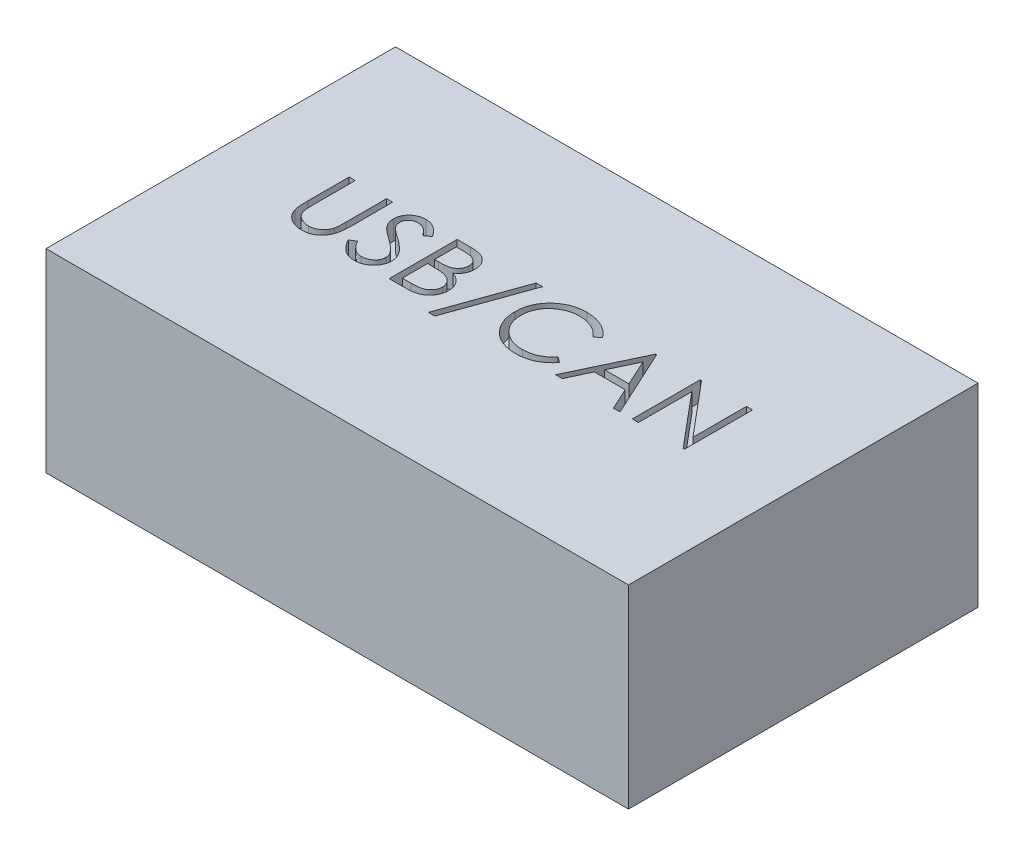
from build123d import *

# Parameters (mm, degrees)
SKETCH1_W           = 30
SKETCH1_H           = 18
BOSS_EXTRUDE1_DEPTH = 10
CUT_EXTRUDE1_DEPTH  = 1


with BuildPart() as part:
    # Sketch1 → Boss-Extrude1 (new body)
    with BuildSketch(Plane(origin=(0, 0, 0), x_dir=(1, 0, 0), z_dir=(0, 1, 0))):
        with Locations((15, 9)):
            Rectangle(SKETCH1_W, SKETCH1_H)
    extrude(amount=BOSS_EXTRUDE1_DEPTH)

    # Sketch2 → Cut-Extrude1 (cut)
    with BuildSketch(Plane(origin=(0, 10, 0), x_dir=(1, 0, 0), z_dir=(0, 1, 0))):
        with BuildLine():
            Line((4.612179487, 11), (4.926282051, 11))
            Line((4.926282051, 11), (4.926282051, 8.902944712))
            add(Edge.make_bspline(
                [(4.926282051, 8.902944712), (4.926235307, 8.873263976), (4.926146603, 8.816939665), (4.926739116, 8.736771364), (4.928398485, 8.665498905), (4.929444644, 8.602847558), (4.931771978, 8.54910481), (4.933670025, 8.5039795), (4.936110582, 8.467685297), (4.939043699, 8.446504371), (4.940304487, 8.43739984)],
                knots=[0, 0, 0, 0, 8.9042e-05, 0.000168973, 0.000240502, 0.000302917, 0.000356945, 0.000401866, 0.000438432, 0.000465999, 0.000465999, 0.000465999, 0.000465999], degree=3))
            add(Edge.make_bspline(
                [(4.940304487, 8.43739984), (4.945481946, 8.404553076), (4.955545132, 8.340710347), (4.98119151, 8.249802065), (5.017009011, 8.167870607), (5.059452054, 8.092359316), (5.115384665, 8.025369956), (5.1823882, 7.963658303), (5.263565969, 7.909686499), (5.353826575, 7.860335687), (5.451111812, 7.820670604), (5.550523079, 7.79067724), (5.650566058, 7.77239834), (5.717542223, 7.770281801), (5.750801282, 7.769230769)],
                knots=[0, 0, 0, 0, 9.971e-05, 0.000193801, 0.000282365, 0.000367504, 0.000452699, 0.000543015, 0.000639862, 0.000744331, 0.000851226, 0.000954377, 0.001055468, 0.001155185, 0.001155185, 0.001155185, 0.001155185], degree=3))
            add(Edge.make_bspline(
                [(5.750801282, 7.769230769), (5.779355022, 7.77030462), (5.836297584, 7.772446118), (5.920904015, 7.785707549), (6.003304124, 7.809608115), (6.083904804, 7.840447873), (6.159455788, 7.881195464), (6.22999923, 7.928266303), (6.292963164, 7.98347718), (6.350421162, 8.044577524), (6.400456098, 8.113517324), (6.44382724, 8.188795462), (6.479353169, 8.271544809), (6.496896694, 8.329699231), (6.505909455, 8.359575321)],
                knots=[0, 0, 0, 0, 8.5678e-05, 0.00017086, 0.000256092, 0.000342674, 0.000429242, 0.000513055, 0.000596556, 0.000679898, 0.000764179, 0.00085149, 0.000940054, 0.001033621, 0.001033621, 0.001033621, 0.001033621], degree=3))
            add(Edge.make_bspline(
                [(6.505909455, 8.359575321), (6.50890958, 8.371923895), (6.515595069, 8.399441495), (6.521842114, 8.445962785), (6.528348639, 8.500852149), (6.532863209, 8.564503962), (6.537264429, 8.636704935), (6.539897502, 8.717831192), (6.541114535, 8.807588153), (6.541477216, 8.870225315), (6.541666667, 8.902944712)],
                knots=[0, 0, 0, 0, 3.81e-05, 8.4902e-05, 0.000140649, 0.000203941, 0.000276279, 0.000357657, 0.000447412, 0.000545571, 0.000545571, 0.000545571, 0.000545571], degree=3))
            Line((6.541666667, 8.902944712), (6.541666667, 11))
            Line((6.541666667, 11), (6.855769231, 11))
            Line((6.855769231, 11), (6.855769231, 8.886117788))
            add(Edge.make_bspline(
                [(6.855769231, 8.886117788), (6.85551511, 8.84801941), (6.855019179, 8.773668107), (6.850718603, 8.664716748), (6.843861603, 8.561363766), (6.834173515, 8.46359527), (6.821336512, 8.371761111), (6.807061291, 8.285056342), (6.788881758, 8.20410335), (6.767648357, 8.128270932), (6.743374809, 8.056085419), (6.71193366, 7.987576804), (6.67650916, 7.920662404), (6.634494508, 7.856354295), (6.587283125, 7.794367742), (6.533831444, 7.735078667), (6.475907283, 7.677539621), (6.412547724, 7.623226555), (6.344797198, 7.573417878), (6.272857241, 7.529620107), (6.197280471, 7.492596489), (6.118263345, 7.462120565), (6.035772142, 7.439205966), (5.949804782, 7.42213081), (5.860165589, 7.412428513), (5.799200933, 7.410986582), (5.768329327, 7.41025641)],
                knots=[0, 0, 0, 0, 0.000114291, 0.000223047, 0.000327049, 0.000424998, 0.000517708, 0.000605194, 0.000688542, 0.000766455, 0.0008414, 0.000916717, 0.000992315, 0.001068354, 0.001146882, 0.001225836, 0.001307639, 0.001391671, 0.001475952, 0.001559641, 0.001643989, 0.001728103, 0.001813335, 0.001900511, 0.00199079, 0.002083404, 0.002083404, 0.002083404, 0.002083404], degree=3))
            add(Edge.make_bspline(
                [(5.768329327, 7.41025641), (5.734660224, 7.411041176), (5.668601565, 7.412580882), (5.571263498, 7.421403632), (5.477949302, 7.438022027), (5.387673425, 7.45918197), (5.301664928, 7.488365708), (5.218771483, 7.522463832), (5.140412802, 7.564341093), (5.065317674, 7.610934486), (4.995492917, 7.663359124), (4.931395514, 7.720499298), (4.872919644, 7.781439675), (4.821050947, 7.846840041), (4.774930063, 7.916191748), (4.735199849, 7.989690988), (4.701086605, 8.067309304), (4.683480038, 8.121262504), (4.674579327, 8.14853766)],
                knots=[0, 0, 0, 0, 0.000101022, 0.000198206, 0.000292839, 0.000385177, 0.00047608, 0.000565014, 0.000653769, 0.000742283, 0.000829923, 0.000915339, 0.000999643, 0.001082971, 0.00116542, 0.001249186, 0.001333332, 0.001419362, 0.001419362, 0.001419362, 0.001419362], degree=3))
            add(Edge.make_bspline(
                [(4.674579327, 8.14853766), (4.669402169, 8.167170235), (4.658172797, 8.207584704), (4.6461475, 8.274471192), (4.636038418, 8.35148611), (4.62653286, 8.438634728), (4.620923902, 8.535984595), (4.616006463, 8.643493511), (4.612144844, 8.761291472), (4.612167617, 8.843345988), (4.612179487, 8.886117788)],
                knots=[0, 0, 0, 0, 5.799e-05, 0.000125782, 0.000203619, 0.000291034, 0.000388694, 0.000496078, 0.000613919, 0.000742226, 0.000742226, 0.000742226, 0.000742226], degree=3))
            Line((4.612179487, 8.886117788), (4.612179487, 11))
        make_face()
        with BuildLine():
            Line((7.394230769, 8.175180288), (7.690104167, 8.352564103))
            add(Edge.make_bspline(
                [(7.690104167, 8.352564103), (7.717622404, 8.306499718), (7.770346285, 8.218242134), (7.858297644, 8.098984093), (7.949430555, 7.997621937), (8.044419888, 7.914745329), (8.142685837, 7.849496442), (8.24486989, 7.803294211), (8.350627701, 7.774478235), (8.422601522, 7.770978149), (8.458533654, 7.769230769)],
                knots=[0, 0, 0, 0, 0.000160901, 0.00030828, 0.000443778, 0.00056903, 0.000685513, 0.000796284, 0.00090427, 0.001011928, 0.001011928, 0.001011928, 0.001011928], degree=3))
            add(Edge.make_bspline(
                [(8.458533654, 7.769230769), (8.489220514, 7.770085442), (8.550057287, 7.771779832), (8.63961953, 7.788060634), (8.726601333, 7.813072763), (8.80920997, 7.848893694), (8.886305585, 7.89223218), (8.95391228, 7.944578358), (9.012358393, 8.003184563), (9.060167508, 8.068567218), (9.096847543, 8.138884367), (9.125039612, 8.211060318), (9.140684685, 8.286228886), (9.143041439, 8.336839349), (9.144230769, 8.362379808)],
                knots=[0, 0, 0, 0, 9.1978e-05, 0.000182347, 0.000272202, 0.000362975, 0.000451852, 0.000536835, 0.000618639, 0.000699414, 0.000778765, 0.000855983, 0.0009312, 0.001007828, 0.001007828, 0.001007828, 0.001007828], degree=3))
            add(Edge.make_bspline(
                [(9.144230769, 8.362379808), (9.142756459, 8.391520657), (9.1397594, 8.450759747), (9.11442792, 8.5381594), (9.074578673, 8.62465197), (9.03781603, 8.678153235), (9.018729968, 8.705929487)],
                knots=[0, 0, 0, 0, 8.7281e-05, 0.000177429, 0.000270909, 0.000371844, 0.000371844, 0.000371844, 0.000371844], degree=3))
            add(Edge.make_bspline(
                [(9.018729968, 8.705929487), (9.003059354, 8.725976311), (8.970160859, 8.768062109), (8.913603347, 8.830707345), (8.847237233, 8.895325764), (8.773333678, 8.964384821), (8.689200589, 9.034672617), (8.597473074, 9.109540895), (8.495809215, 9.186142472), (8.424509719, 9.237515038), (8.387720353, 9.264022436)],
                knots=[0, 0, 0, 0, 7.6319e-05, 0.000160223, 0.000252933, 0.000354147, 0.000463581, 0.000581729, 0.000709336, 0.000845369, 0.000845369, 0.000845369, 0.000845369], degree=3))
            add(Edge.make_bspline(
                [(8.387720353, 9.264022436), (8.350896356, 9.290251024), (8.28049168, 9.340398086), (8.182033097, 9.41482237), (8.093988634, 9.482866239), (8.016749618, 9.545170251), (7.950350021, 9.601742856), (7.89426661, 9.652040795), (7.849928053, 9.697424356), (7.825272472, 9.726865698), (7.814202724, 9.740084135)],
                knots=[0, 0, 0, 0, 0.000135623, 0.000259301, 0.000370234, 0.000469439, 0.00055697, 0.000631911, 0.000695377, 0.00074709, 0.00074709, 0.00074709, 0.00074709], degree=3))
            add(Edge.make_bspline(
                [(7.814202724, 9.740084135), (7.798730179, 9.760685171), (7.768301342, 9.801199875), (7.728135337, 9.864524733), (7.693996174, 9.929347998), (7.667233842, 9.995843863), (7.644697623, 10.063078792), (7.629539692, 10.131930038), (7.620048296, 10.202088656), (7.619076309, 10.249302157), (7.618589744, 10.272936699)],
                knots=[0, 0, 0, 0, 7.727e-05, 0.000151962, 0.000224716, 0.000296717, 0.00036678, 0.0004372, 0.000507902, 0.000578771, 0.000578771, 0.000578771, 0.000578771], degree=3))
            add(Edge.make_bspline(
                [(7.618589744, 10.272936699), (7.619894953, 10.309966473), (7.622477473, 10.383234537), (7.64431799, 10.490265367), (7.678790884, 10.592451785), (7.727085771, 10.688782118), (7.789343124, 10.776748099), (7.861389099, 10.857361586), (7.947200585, 10.925130168), (8.041353208, 10.984342227), (8.14440958, 11.030688152), (8.252400484, 11.065649132), (8.365497556, 11.08545839), (8.44210069, 11.088301155), (8.480969551, 11.08974359)],
                knots=[0, 0, 0, 0, 0.000110999, 0.000219625, 0.000326272, 0.00043382, 0.000541574, 0.000648775, 0.000756959, 0.000868438, 0.000981703, 0.00109501, 0.001208203, 0.0013248, 0.0013248, 0.0013248, 0.0013248], degree=3))
            add(Edge.make_bspline(
                [(8.480969551, 11.08974359), (8.522213652, 11.088321038), (8.604235003, 11.085492037), (8.724884219, 11.060894506), (8.841044935, 11.020193834), (8.9344882, 10.974005176), (9.007620962, 10.92787376), (9.063393694, 10.885853936), (9.119911145, 10.837478827), (9.1776292, 10.782619581), (9.235569859, 10.72077283), (9.294593312, 10.652362141), (9.35483758, 10.577805585), (9.393593441, 10.524581085), (9.413461538, 10.497295673)],
                knots=[0, 0, 0, 0, 0.000123638, 0.000245877, 0.000367608, 0.000492088, 0.000557638, 0.000626769, 0.000701372, 0.00078072, 0.000865532, 0.000955497, 0.001051745, 0.001152989, 0.001152989, 0.001152989, 0.001152989], degree=3))
            Line((9.413461538, 10.497295673), (9.129507212, 10.282051282))
            add(Edge.make_bspline(
                [(9.129507212, 10.282051282), (9.112361279, 10.304139972), (9.079342222, 10.346677626), (9.029212735, 10.406248941), (8.981964087, 10.460665421), (8.935413687, 10.507930549), (8.892020056, 10.550632682), (8.849903014, 10.587192439), (8.809668662, 10.617968034), (8.758951752, 10.650811594), (8.695234034, 10.683368098), (8.615249497, 10.710917176), (8.531663222, 10.727472238), (8.474733591, 10.729661126), (8.445913462, 10.730769231)],
                knots=[0, 0, 0, 0, 8.3877e-05, 0.000161528, 0.000233552, 0.000299993, 0.000360485, 0.000416152, 0.000467195, 0.000512312, 0.000597287, 0.000681099, 0.000765389, 0.000851809, 0.000851809, 0.000851809, 0.000851809], degree=3))
            add(Edge.make_bspline(
                [(8.445913462, 10.730769231), (8.409756939, 10.729557531), (8.340032492, 10.727220882), (8.241042256, 10.701700896), (8.151948331, 10.661519036), (8.075395765, 10.605204058), (8.011658788, 10.538483065), (7.96555333, 10.46170421), (7.937803165, 10.376921808), (7.934416885, 10.317780151), (7.932692308, 10.287660256)],
                knots=[0, 0, 0, 0, 0.000108248, 0.000208746, 0.00030443, 0.000399793, 0.000492054, 0.00057947, 0.000666386, 0.000756591, 0.000756591, 0.000756591, 0.000756591], degree=3))
            add(Edge.make_bspline(
                [(7.932692308, 10.287660256), (7.933085434, 10.268908778), (7.93387233, 10.231375158), (7.944847128, 10.175923736), (7.958946457, 10.120612397), (7.981289089, 10.065689814), (8.012134392, 10.010195455), (8.052639568, 9.953173718), (8.10365288, 9.894122009), (8.142729893, 9.855714635), (8.163361378, 9.835436699)],
                knots=[0, 0, 0, 0, 5.616e-05, 0.000112411, 0.000169046, 0.000227244, 0.000289691, 0.000359134, 0.000436702, 0.000523463, 0.000523463, 0.000523463, 0.000523463], degree=3))
            add(Edge.make_bspline(
                [(8.163361378, 9.835436699), (8.171022751, 9.828599673), (8.189224418, 9.812356465), (8.222500343, 9.785764184), (8.266443142, 9.752961412), (8.319905343, 9.712374095), (8.383872705, 9.665292633), (8.458352261, 9.612319021), (8.542513794, 9.551733562), (8.60223571, 9.509376021), (8.633814103, 9.486979167)],
                knots=[0, 0, 0, 0, 3.0802e-05, 7.3177e-05, 0.000127725, 0.000195314, 0.000274544, 0.000365991, 0.000469501, 0.000585644, 0.000585644, 0.000585644, 0.000585644], degree=3))
            add(Edge.make_bspline(
                [(8.633814103, 9.486979167), (8.671800016, 9.459337807), (8.745354472, 9.405814145), (8.850012052, 9.325398465), (8.94490586, 9.246750697), (9.030369064, 9.17037309), (9.107245972, 9.096844997), (9.174683693, 9.025281816), (9.233369373, 8.956196244), (9.296548592, 8.867623668), (9.361106411, 8.758842584), (9.416547919, 8.625564345), (9.451506266, 8.491768025), (9.456077782, 8.401841188), (9.458333333, 8.357471955)],
                knots=[0, 0, 0, 0, 0.000140932, 0.000272896, 0.000395881, 0.000510584, 0.000616697, 0.000714904, 0.000805482, 0.000888372, 0.001041088, 0.001183793, 0.001320341, 0.001453327, 0.001453327, 0.001453327, 0.001453327], degree=3))
            add(Edge.make_bspline(
                [(9.458333333, 8.357471955), (9.457676195, 8.32609359), (9.45637468, 8.263946206), (9.441413766, 8.17269113), (9.419494101, 8.08406026), (9.386456867, 7.999149147), (9.346133709, 7.916404385), (9.294967461, 7.837996484), (9.235659776, 7.762190086), (9.167626011, 7.691006594), (9.093180109, 7.625660398), (9.014496415, 7.567531337), (8.931446142, 7.519063014), (8.844479825, 7.479512172), (8.753577488, 7.448578654), (8.658769704, 7.426165785), (8.559900193, 7.412410074), (8.492699712, 7.410982313), (8.458533654, 7.41025641)],
                knots=[0, 0, 0, 0, 9.4044e-05, 0.000186263, 0.000276729, 0.000367488, 0.000459046, 0.000552398, 0.000647774, 0.000747454, 0.000847311, 0.000944634, 0.001040472, 0.001135227, 0.001230788, 0.001328063, 0.00142712, 0.00152957, 0.00152957, 0.00152957, 0.00152957], degree=3))
            add(Edge.make_bspline(
                [(8.458533654, 7.41025641), (8.432098311, 7.410767592), (8.379560551, 7.411783517), (8.301851069, 7.420764798), (8.22571148, 7.433471901), (8.152097198, 7.453645971), (8.080059786, 7.478122948), (8.009912552, 7.508261281), (7.941621498, 7.544378482), (7.874803915, 7.585673507), (7.80962974, 7.633731252), (7.746710272, 7.689704748), (7.683981087, 7.752050253), (7.62329369, 7.822460816), (7.563420546, 7.899798899), (7.505542137, 7.984788083), (7.448460419, 8.076965436), (7.412644951, 8.141830522), (7.394230769, 8.175180288)],
                knots=[0, 0, 0, 0, 7.9276e-05, 0.000157554, 0.000234438, 0.000310629, 0.000386236, 0.000462555, 0.000539392, 0.000617798, 0.000698008, 0.000781971, 0.000870217, 0.00096315, 0.001060616, 0.001163492, 0.001271478, 0.00138575, 0.00138575, 0.00138575, 0.00138575], degree=3))
        make_face()
        with BuildLine():
            Line((10.176282051, 11), (10.859174679, 11))
            add(Edge.make_bspline(
                [(10.859174679, 11), (10.892603158, 10.99982425), (10.957395868, 10.999483602), (11.05161531, 10.99420047), (11.13986412, 10.986996801), (11.222167893, 10.975566708), (11.298488595, 10.961774931), (11.369056232, 10.945073115), (11.433646405, 10.925046501), (11.510759141, 10.89320022), (11.598679802, 10.845877051), (11.693878195, 10.775948486), (11.775282434, 10.690416023), (11.845468751, 10.593933368), (11.901269871, 10.487797596), (11.941639168, 10.374538407), (11.967197044, 10.255616665), (11.969825478, 10.173973487), (11.971153846, 10.13271234)],
                knots=[0, 0, 0, 0, 0.00010027, 0.000194349, 0.000283026, 0.000365821, 0.000443519, 0.000515622, 0.000583254, 0.00064614, 0.000765662, 0.000881909, 0.000998927, 0.001118415, 0.001238844, 0.00135727, 0.001478274, 0.001601912, 0.001601912, 0.001601912, 0.001601912], degree=3))
            add(Edge.make_bspline(
                [(11.971153846, 10.13271234), (11.970060628, 10.094059784), (11.96791235, 10.018103867), (11.947369591, 9.907009758), (11.915208923, 9.801258539), (11.870503673, 9.701236154), (11.812401677, 9.60920254), (11.743543359, 9.524415274), (11.660466556, 9.450464217), (11.598223316, 9.409121315), (11.566606571, 9.388120994)],
                knots=[0, 0, 0, 0, 0.000115857, 0.00022767, 0.000337672, 0.000446877, 0.000555233, 0.000663318, 0.000773539, 0.000887324, 0.000887324, 0.000887324, 0.000887324], degree=3))
            add(Edge.make_bspline(
                [(11.566606571, 9.388120994), (11.606366998, 9.372855995), (11.682438545, 9.34365027), (11.787124558, 9.292014806), (11.877319403, 9.235852696), (11.953716549, 9.174520846), (12.019054204, 9.108412035), (12.076107145, 9.036556921), (12.12478852, 8.958018163), (12.166501443, 8.873614627), (12.199050199, 8.784208159), (12.223426104, 8.690637383), (12.237393553, 8.593237828), (12.239381194, 8.526952448), (12.240384615, 8.493489583)],
                knots=[0, 0, 0, 0, 0.000127722, 0.000244363, 0.000349599, 0.000445847, 0.000537565, 0.000627901, 0.000720503, 0.000814257, 0.000909859, 0.001005428, 0.001103887, 0.001204268, 0.001204268, 0.001204268, 0.001204268], degree=3))
            add(Edge.make_bspline(
                [(12.240384615, 8.493489583), (12.239407769, 8.459322711), (12.237485797, 8.392098433), (12.223305826, 8.293343299), (12.199296719, 8.198968352), (12.166225572, 8.108363169), (12.123063258, 8.021703035), (12.070535293, 7.938889771), (12.00790373, 7.86075544), (11.937840861, 7.786431817), (11.858578715, 7.71960403), (11.77306296, 7.660088323), (11.68021664, 7.611142261), (11.581564646, 7.570026239), (11.47600033, 7.538619041), (11.363997723, 7.516646467), (11.245653421, 7.50184143), (11.16444367, 7.500624225), (11.122796474, 7.5)],
                knots=[0, 0, 0, 0, 0.000102481, 0.000201635, 0.000298562, 0.000394165, 0.000490425, 0.000588455, 0.000687769, 0.000790423, 0.000894381, 0.000998232, 0.001102369, 0.001208616, 0.001318415, 0.001432129, 0.001550749, 0.00167562, 0.00167562, 0.00167562, 0.00167562], degree=3))
            Line((11.122796474, 7.5), (10.176282051, 7.5))
            Line((10.176282051, 7.5), (10.176282051, 11))
        make_face()
        with BuildLine():
            Line((10.490384615, 10.641025641), (10.490384615, 9.519230769))
            Line((10.490384615, 9.519230769), (10.701422276, 9.519230769))
            add(Edge.make_bspline(
                [(10.701422276, 9.519230769), (10.732271071, 9.519630692), (10.79187723, 9.520403425), (10.878197127, 9.522616942), (10.958322145, 9.528814985), (11.032113978, 9.535011248), (11.099456422, 9.545085835), (11.160200284, 9.557077958), (11.21529888, 9.569760863), (11.278838426, 9.59133035), (11.350911374, 9.623208025), (11.427744479, 9.672679861), (11.495478948, 9.731604215), (11.552676136, 9.799595176), (11.599487606, 9.874461362), (11.632001322, 9.955008243), (11.654048606, 10.039228375), (11.656040137, 10.097046627), (11.657051282, 10.126402244)],
                knots=[0, 0, 0, 0, 9.2559e-05, 0.000178842, 0.000258967, 0.000333616, 0.000400942, 0.000463093, 0.000519379, 0.000570374, 0.000664201, 0.000755025, 0.000843472, 0.000932526, 0.001020669, 0.001107124, 0.001192318, 0.001280185, 0.001280185, 0.001280185, 0.001280185], degree=3))
            add(Edge.make_bspline(
                [(11.657051282, 10.126402244), (11.656525102, 10.145828015), (11.655492942, 10.183933787), (11.647039639, 10.239483141), (11.632672065, 10.291726894), (11.614217772, 10.341381004), (11.588429083, 10.386892854), (11.55806562, 10.42983605), (11.521379929, 10.468748169), (11.479622617, 10.505117667), (11.431613994, 10.537362195), (11.377382702, 10.565602958), (11.316195025, 10.588343735), (11.24908217, 10.608259887), (11.175011083, 10.622248181), (11.094836529, 10.633901569), (11.00790181, 10.639834311), (10.947756708, 10.640619673), (10.916666667, 10.641025641)],
                knots=[0, 0, 0, 0, 5.8261e-05, 0.000114285, 0.000168029, 0.000220632, 0.000272728, 0.000324483, 0.000378062, 0.000432741, 0.000490301, 0.000551137, 0.000615721, 0.000685833, 0.000760908, 0.00084162, 0.000928788, 0.00102206, 0.00102206, 0.00102206, 0.00102206], degree=3))
            Line((10.916666667, 10.641025641), (10.490384615, 10.641025641))
        make_face(mode=Mode.SUBTRACT)
        with BuildLine():
            Line((10.490384615, 9.16025641), (10.490384615, 7.858974359))
            Line((10.490384615, 7.858974359), (10.937700321, 7.858974359))
            add(Edge.make_bspline(
                [(10.937700321, 7.858974359), (10.969719246, 7.859358106), (11.031431505, 7.860097729), (11.120532735, 7.862512283), (11.203115839, 7.868004559), (11.278803975, 7.876650409), (11.348414427, 7.886028858), (11.41111213, 7.898640139), (11.467405324, 7.913089099), (11.532679632, 7.935423272), (11.60618314, 7.970119743), (11.685393996, 8.022433969), (11.755820214, 8.084757277), (11.815625474, 8.156888191), (11.864638462, 8.235319518), (11.900293917, 8.318464868), (11.922284774, 8.404950395), (11.924946943, 8.463917108), (11.926282051, 8.493489583)],
                knots=[0, 0, 0, 0, 9.6064e-05, 0.000185151, 0.000267373, 0.000344257, 0.000413665, 0.000478015, 0.000536005, 0.000587888, 0.000684801, 0.000778918, 0.000871787, 0.000965866, 0.001059062, 0.00114827, 0.001236355, 0.001324974, 0.001324974, 0.001324974, 0.001324974], degree=3))
            add(Edge.make_bspline(
                [(11.926282051, 8.493489583), (11.926005947, 8.511982924), (11.925458192, 8.548671306), (11.917197577, 8.602587125), (11.905183707, 8.654812998), (11.889652273, 8.705490739), (11.867032806, 8.753704115), (11.840626261, 8.800406674), (11.80966486, 8.845660154), (11.761420694, 8.902872407), (11.691248709, 8.96878942), (11.591541934, 9.033326923), (11.478169636, 9.08537473), (11.395942143, 9.107474206), (11.353465545, 9.118890224)],
                knots=[0, 0, 0, 0, 5.5429e-05, 0.000109963, 0.000163198, 0.000216191, 0.000268588, 0.000322593, 0.000377046, 0.000432793, 0.000546889, 0.000664343, 0.000787646, 0.000919405, 0.000919405, 0.000919405, 0.000919405], degree=3))
            add(Edge.make_bspline(
                [(11.353465545, 9.118890224), (11.336436449, 9.122345308), (11.299513857, 9.129836643), (11.239306276, 9.137744346), (11.170570407, 9.144789406), (11.09314753, 9.150000564), (11.006939689, 9.155387107), (10.91176277, 9.157481929), (10.808005456, 9.159981189), (10.736013083, 9.160162323), (10.698617788, 9.16025641)],
                knots=[0, 0, 0, 0, 5.2115e-05, 0.000112995, 0.000182062, 0.000259389, 0.000345767, 0.00044116, 0.000544948, 0.000657129, 0.000657129, 0.000657129, 0.000657129], degree=3))
            Line((10.698617788, 9.16025641), (10.490384615, 9.16025641))
        make_face(mode=Mode.SUBTRACT)
        Polygon((14.483974359, 11.08974359), (13.020032051, 7.006410256), (12.689102564, 7.006410256), (14.153044872, 11.08974359), align=None)
        with BuildLine():
            Line((18.298076923, 10.357772436), (18.023237179, 10.147435897))
            add(Edge.make_bspline(
                [(18.023237179, 10.147435897), (18.003631291, 10.170801867), (17.964683844, 10.217218783), (17.902024642, 10.282398327), (17.836722999, 10.343463589), (17.768803878, 10.400705469), (17.697044758, 10.452122234), (17.62318396, 10.500393337), (17.545985914, 10.543661075), (17.43923418, 10.596124061), (17.299586331, 10.650870216), (17.123791492, 10.696773448), (16.940280394, 10.725994623), (16.815082794, 10.729159465), (16.751402244, 10.730769231)],
                knots=[0, 0, 0, 0, 9.1485e-05, 0.000181737, 0.000271024, 0.000359627, 0.000447979, 0.000535687, 0.000624217, 0.000713268, 0.000892422, 0.00107303, 0.001257466, 0.001448389, 0.001448389, 0.001448389, 0.001448389], degree=3))
            add(Edge.make_bspline(
                [(16.751402244, 10.730769231), (16.716318944, 10.730365268), (16.646477952, 10.729561092), (16.542829478, 10.718951967), (16.441116427, 10.704040757), (16.341404961, 10.681915434), (16.243822002, 10.653942815), (16.1477296, 10.620517401), (16.054519, 10.579162561), (15.962900762, 10.533454301), (15.875121551, 10.481826856), (15.792066503, 10.425513504), (15.714038536, 10.365144408), (15.640975923, 10.300493302), (15.572803975, 10.231851341), (15.510016664, 10.158487), (15.452831254, 10.080634826), (15.400114229, 9.999321419), (15.352901496, 9.914783627), (15.313371616, 9.826708556), (15.278366494, 9.736604453), (15.250667251, 9.643453293), (15.228742734, 9.547910527), (15.213615071, 9.449719739), (15.2031266, 9.349086059), (15.202326423, 9.280876747), (15.201923077, 9.246494391)],
                knots=[0, 0, 0, 0, 0.000105206, 0.000209435, 0.000312261, 0.00041348, 0.000515565, 0.000616682, 0.000718413, 0.000821258, 0.000923708, 0.001023662, 0.001122111, 0.001219464, 0.00131614, 0.001412112, 0.001508869, 0.001605718, 0.001702691, 0.001799013, 0.001895107, 0.001992482, 0.002090281, 0.00218895, 0.002290387, 0.00239349, 0.00239349, 0.00239349, 0.00239349], degree=3))
            add(Edge.make_bspline(
                [(15.201923077, 9.246494391), (15.203184896, 9.194763071), (15.20566231, 9.093195486), (15.227710644, 8.944424876), (15.261215736, 8.801904202), (15.311431313, 8.66652436), (15.373350363, 8.536616002), (15.451590975, 8.414377148), (15.542207512, 8.297960584), (15.646481931, 8.190117636), (15.760887747, 8.091603911), (15.883635659, 8.004853329), (16.014419947, 7.932538447), (16.151796577, 7.8723625), (16.296822691, 7.826105772), (16.449237493, 7.793541649), (16.608709489, 7.772299468), (16.717678888, 7.77026578), (16.773137019, 7.769230769)],
                knots=[0, 0, 0, 0, 0.000155106, 0.000304531, 0.000450265, 0.000593548, 0.000736853, 0.000881182, 0.001028026, 0.001178769, 0.001330408, 0.001480379, 0.001628835, 0.001777978, 0.001929641, 0.002084627, 0.002245075, 0.00241136, 0.00241136, 0.00241136, 0.00241136], degree=3))
            add(Edge.make_bspline(
                [(16.773137019, 7.769230769), (16.834239708, 7.770919549), (16.954504417, 7.774243472), (17.130872443, 7.802402721), (17.299708209, 7.848060638), (17.461020796, 7.911958561), (17.614355442, 7.995023849), (17.759952102, 8.095721726), (17.897933673, 8.215010059), (17.980904955, 8.306093187), (18.023237179, 8.352564103)],
                knots=[0, 0, 0, 0, 0.00018322, 0.00036062, 0.000534275, 0.000707044, 0.000879893, 0.001056289, 0.001237208, 0.001425665, 0.001425665, 0.001425665, 0.001425665], degree=3))
            Line((18.023237179, 8.352564103), (18.298076923, 8.144330929))
            add(Edge.make_bspline(
                [(18.298076923, 8.144330929), (18.275958813, 8.115792478), (18.231828538, 8.058852271), (18.160370521, 7.978580562), (18.085093224, 7.903076526), (18.005437514, 7.832948905), (17.922319722, 7.766794439), (17.83424741, 7.706492608), (17.742378377, 7.651201724), (17.647023898, 7.600574799), (17.548285285, 7.555657552), (17.44628085, 7.517203784), (17.341450275, 7.484078895), (17.233788767, 7.456826958), (17.12307301, 7.435555874), (17.009702536, 7.421336199), (16.89343266, 7.411594285), (16.814991239, 7.410706369), (16.775240385, 7.41025641)],
                knots=[0, 0, 0, 0, 0.000108293, 0.000216068, 0.000322162, 0.000427957, 0.000534281, 0.00064066, 0.000747915, 0.000855806, 0.000964371, 0.001073102, 0.001182643, 0.001294024, 0.001406092, 0.001520624, 0.001636667, 0.001755891, 0.001755891, 0.001755891, 0.001755891], degree=3))
            add(Edge.make_bspline(
                [(16.775240385, 7.41025641), (16.737596718, 7.410518403), (16.663161027, 7.411036461), (16.553262276, 7.419428628), (16.446272695, 7.430878365), (16.342498069, 7.448118496), (16.241372094, 7.468462836), (16.14381151, 7.495734093), (16.048856299, 7.526283259), (15.956887959, 7.562188246), (15.867828259, 7.602704429), (15.781964447, 7.648495987), (15.699336015, 7.699177852), (15.619130594, 7.753632863), (15.54253301, 7.813610164), (15.468879485, 7.878276799), (15.397757009, 7.94741481), (15.353754324, 7.997269663), (15.331630609, 8.022335737)],
                knots=[0, 0, 0, 0, 0.0001129, 0.000223246, 0.000330481, 0.000435603, 0.000538732, 0.000639764, 0.000739316, 0.000837878, 0.000935767, 0.001032686, 0.001129604, 0.00122645, 0.001323362, 0.001421241, 0.001520399, 0.001620667, 0.001620667, 0.001620667, 0.001620667], degree=3))
            add(Edge.make_bspline(
                [(15.331630609, 8.022335737), (15.296194965, 8.065876926), (15.225751489, 8.152433637), (15.135625805, 8.292719618), (15.05847825, 8.439187827), (14.996102329, 8.592607755), (14.947339596, 8.752635143), (14.913558401, 8.919350657), (14.891606796, 9.092598599), (14.889096508, 9.210435388), (14.887820513, 9.270332532)],
                knots=[0, 0, 0, 0, 0.000168306, 0.00033458, 0.000499224, 0.000664315, 0.00083066, 0.00100034, 0.001174094, 0.001353718, 0.001353718, 0.001353718, 0.001353718], degree=3))
            add(Edge.make_bspline(
                [(14.887820513, 9.270332532), (14.889375706, 9.333287986), (14.892435453, 9.45714891), (14.918431248, 9.638922863), (14.960250044, 9.813074262), (15.019646933, 9.979278007), (15.094952284, 10.138408287), (15.187978898, 10.289249492), (15.29764604, 10.432766292), (15.423093608, 10.566781043), (15.560660943, 10.689320396), (15.707979757, 10.797126599), (15.864761704, 10.886844115), (16.029279556, 10.961840278), (16.202765237, 11.019484741), (16.384848606, 11.059837928), (16.575187521, 11.084955044), (16.705049947, 11.088130252), (16.771033654, 11.08974359)],
                knots=[0, 0, 0, 0, 0.000188789, 0.000371431, 0.000549644, 0.000725278, 0.00089996, 0.001076844, 0.001255917, 0.001440951, 0.001626689, 0.001807878, 0.001987546, 0.002167657, 0.002349462, 0.002534866, 0.002726448, 0.002924344, 0.002924344, 0.002924344, 0.002924344], degree=3))
            add(Edge.make_bspline(
                [(16.771033654, 11.08974359), (16.811248126, 11.089261452), (16.890848623, 11.088307108), (17.008601275, 11.079000965), (17.123243602, 11.063487359), (17.234854584, 11.042371289), (17.343977201, 11.016163968), (17.449777442, 10.98202367), (17.552876128, 10.942987138), (17.652623037, 10.898028672), (17.748539587, 10.847561931), (17.840595905, 10.792146307), (17.928060764, 10.731850502), (18.011549612, 10.667187326), (18.089665823, 10.596788767), (18.164627302, 10.522591171), (18.23388838, 10.442457347), (18.276641575, 10.386052413), (18.298076923, 10.357772436)],
                knots=[0, 0, 0, 0, 0.000120626, 0.000238766, 0.000354085, 0.000467531, 0.000579423, 0.000690512, 0.000800803, 0.000910007, 0.001018518, 0.001125773, 0.001232152, 0.001337058, 0.001442329, 0.001547432, 0.001653292, 0.001759736, 0.001759736, 0.001759736, 0.001759736], degree=3))
        make_face()
        Polygon((20.451923077, 11), (22.067307692, 7.5), (21.725861378, 7.5), (21.208433494, 8.621794872), (19.621794872, 8.621794872), (19.090344551, 7.5), (18.746794872, 7.5), (20.407051282, 11), align=None)
        Polygon((20.425981571, 10.317107372), (19.79286859, 8.980769231), (21.04296875, 8.980769231), align=None, mode=Mode.SUBTRACT)
        Polygon((22.695512821, 7.5), (22.695512821, 11), (22.761418269, 11), (25.073717949, 8.245292468), (25.073717949, 11), (25.387820513, 11), (25.387820513, 7.5), (25.31630609, 7.5), (23.009615385, 10.248397436), (23.009615385, 7.5), align=None)
    extrude(amount=-CUT_EXTRUDE1_DEPTH, mode=Mode.SUBTRACT)


solid = part.part
